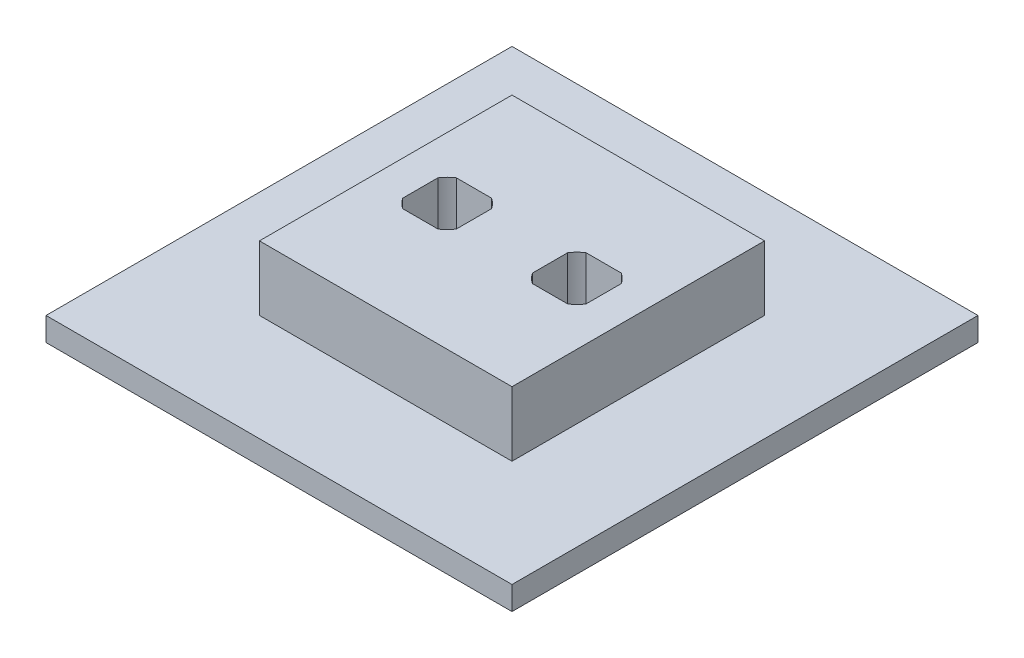
from build123d import *

# Parameters (mm, degrees)
SKETCH1_W               = 79.375
SKETCH1_H               = 79.375
BOSS_EXTRUDE1_DEPTH     = 4
SKETCH2_W               = 43.02
SKETCH2_H               = 43.02
SKETCH2_R               = 5.461
BOSS_EXTRUDE2_DEPTH     = 11
SKETCH3_R               = 5.461
CUT_EXTRUDE1_DEPTH      = 1
CUT_EXTRUDE1_DEPTH_BACK = 16
SKETCH4_W               = 38.805624494
SKETCH4_H               = 17.902161279
SKETCH4_W_2             = 9.122
SKETCH4_H_2             = 9.122
BOSS_EXTRUDE3_DEPTH     = 15


with BuildPart() as part:
    # Sketch1 → Boss-Extrude1 (new body)
    with BuildSketch(Plane(origin=(0, 0, 0), x_dir=(1, 0, 0), z_dir=(0, 1, 0))):
        with Locations((39.6875, 39.6875)):
            Rectangle(SKETCH1_W, SKETCH1_H)
    extrude(amount=BOSS_EXTRUDE1_DEPTH)

    # Sketch2 → Boss-Extrude2 (add)
    with BuildSketch(Plane(origin=(0, 4, 0), x_dir=(1, 0, 0), z_dir=(0, 1, 0))):
        with Locations((39.6875, 39.6875)):
            Rectangle(SKETCH2_W, SKETCH2_H)
        with Locations((28.6385, 39.6875)):
            Circle(SKETCH2_R, mode=Mode.SUBTRACT)
        with Locations((50.7365, 39.6875)):
            Circle(SKETCH2_R, mode=Mode.SUBTRACT)
    extrude(amount=BOSS_EXTRUDE2_DEPTH)

    # Sketch3 → Cut-Extrude1 (cut, two sides)
    with BuildSketch(Plane(origin=(0, 15, 0), x_dir=(1, 0, 0), z_dir=(0, 1, 0))) as cut_extrude1_sk:
        with Locations((28.6385, 39.6875)):
            Circle(SKETCH3_R)
        with Locations((50.7365, 39.6875)):
            Circle(SKETCH3_R)
    extrude(amount=CUT_EXTRUDE1_DEPTH, mode=Mode.SUBTRACT)
    extrude(cut_extrude1_sk.sketch, amount=-CUT_EXTRUDE1_DEPTH_BACK, mode=Mode.SUBTRACT)

    # Sketch4 → Boss-Extrude3 (add)
    with BuildSketch(Plane(origin=(0, 15, 0), x_dir=(1, 0, 0), z_dir=(0, 1, 0))):
        with Locations((39.727968959, 38.830978853)):
            Rectangle(SKETCH4_W, SKETCH4_H)
        with Locations((28.6385, 39.6875)):
            Rectangle(SKETCH4_W_2, SKETCH4_H_2, mode=Mode.SUBTRACT)
        with Locations((50.7365, 39.6875)):
            Rectangle(SKETCH4_W_2, SKETCH4_H_2, mode=Mode.SUBTRACT)
    extrude(amount=-BOSS_EXTRUDE3_DEPTH)


solid = part.part
